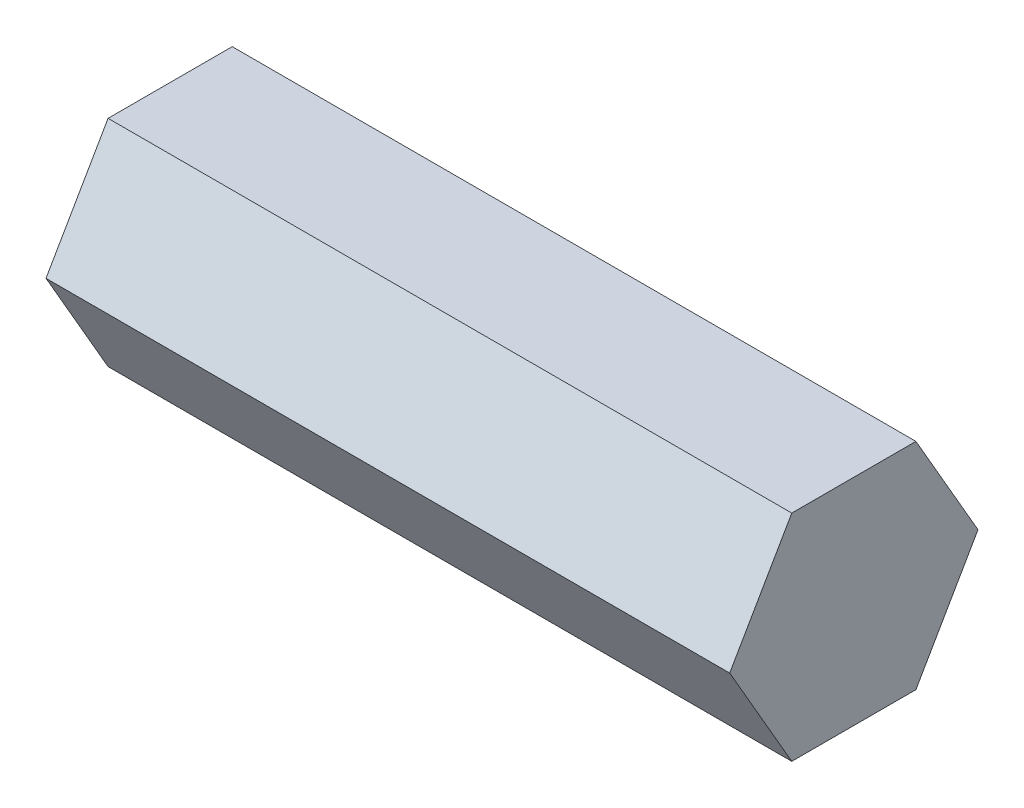
from build123d import *

# Parameters (mm, degrees)
BOSS_EXTRUDE1_DEPTH = 40.38


with BuildPart() as part:
    # Sketch1 → Boss-Extrude1 (new body)
    with BuildSketch(Plane(origin=(0, 0, 0), x_dir=(0, 0, -1), z_dir=(1, 0, 0))):
        Polygon((7.332348419, 0), (3.666174209, 6.35), (-3.666174209, 6.35), (-7.332348419, 0), (-3.666174209, -6.35), (3.666174209, -6.35), align=None)
    extrude(amount=BOSS_EXTRUDE1_DEPTH)


solid = part.part
